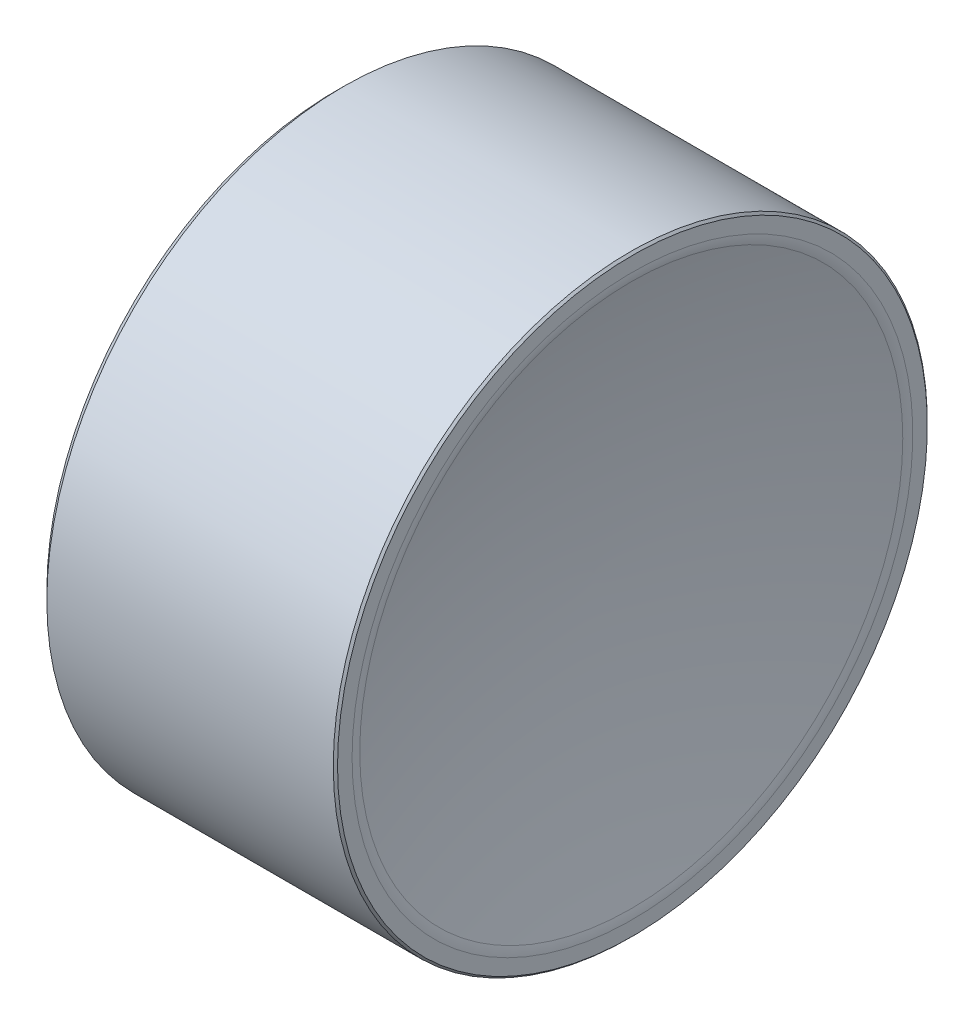
from build123d import *

# Parameters (mm, degrees)
CHAMFER2_SIZE = 0.635
CHAMFER3_SIZE = 0.15875
FILLET1_R     = 2.54
FILLET2_R     = 0.635


with BuildPart() as part:
    # Sketch1 → Revolve1 (revolve)
    with BuildSketch(Plane.XY):
        with BuildLine():
            Line((-2.621306193, 22.225), (-1.294558461, 22.225))
            ThreePointArc((-1.294558461, 22.225), (-0.519789241, 32.63679423), (1.5875, 42.8625))
            Line((1.5875, 42.8625), (1.5875, 44.45))
            Line((1.5875, 44.45), (-20.6375, 44.45))
            Line((-20.6375, 44.45), (-20.6375, 42.8625))
            Line((-20.6375, 42.8625), (0, 42.8625))
            ThreePointArc((0, 42.8625), (-1.963357619, 32.626654344), (-2.621306193, 22.225))
        make_face()
    revolve(axis=Axis((-2.621306193, 22.225, 0), (1, 0, 0)))

    # Chamfer2
    chamfer2_edges = [part.edges().sort_by_distance(p)[0] for p in [
        (-20.6375, 0, 0),
    ]]
    chamfer(chamfer2_edges, length=CHAMFER2_SIZE)

    # Chamfer3
    chamfer3_edges = [part.edges().sort_by_distance(p)[0] for p in [
        (1.5875, 0, 0),
        (-20.6375, 1.5875, 0),
    ]]
    chamfer(chamfer3_edges, length=CHAMFER3_SIZE)

    # Fillet1
    fillet1_edges = [part.edges().sort_by_distance(p)[0] for p in [
        (1.5875, 1.5875, 0),
    ]]
    fillet(fillet1_edges, radius=FILLET1_R)

    # Fillet2
    fillet2_edges = [part.edges().sort_by_distance(p)[0] for p in [
        (0, 1.5875, 0),
    ]]
    fillet(fillet2_edges, radius=FILLET2_R)


solid = part.part
